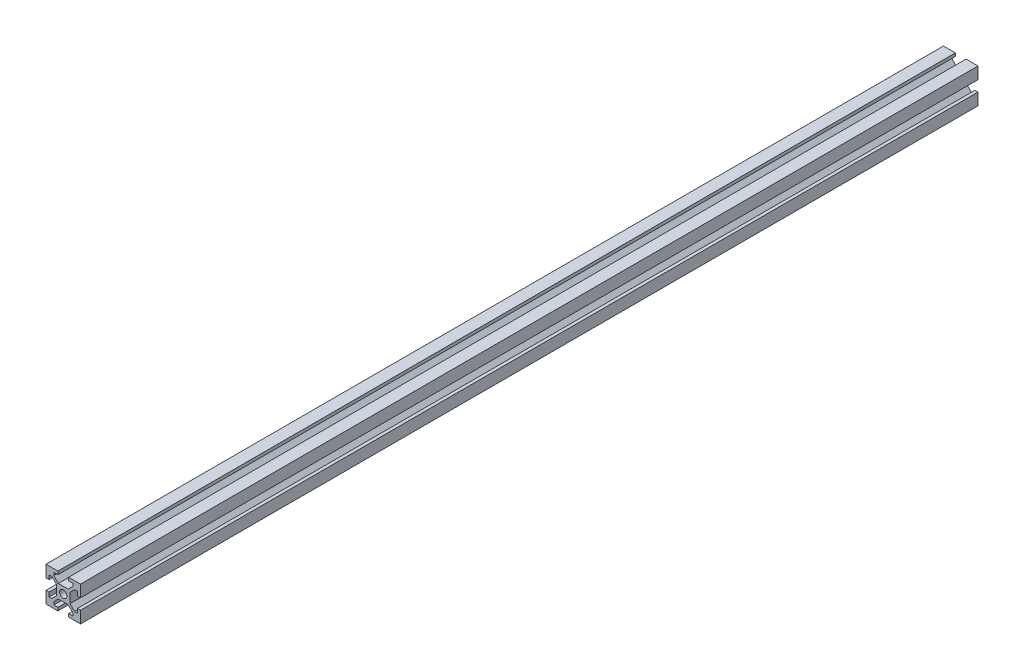
from build123d import *

# Parameters (mm, degrees)
BOSS_EXTRUDE1_DEPTH = 520
SKETCH2_R           = 2.1
CUT_EXTRUDE1_DEPTH  = 521
SKETCH3_R           = 2.1
CUT_EXTRUDE2_DEPTH  = 14.900660172


with BuildPart() as part:
    # Sketch1 → Boss-Extrude1 (new body)
    with BuildSketch(Plane.XY):
        Polygon((-3.1, 10), (-3.1, 8.200660172), (-5.5, 8.200660172), (-5.5, 6.560660172), (-2.84, 3.900660172), (2.84, 3.900660172), (5.5, 6.560660172), (5.5, 8.200660172), (3.1, 8.200660172), (3.1, 10), (10, 10), (10, 3.1), (8.200660172, 3.1), (8.200660172, 5.5), (6.560660172, 5.5), (3.900660172, 2.84), (3.900660172, -2.84), (6.560660172, -5.5), (8.200660172, -5.5), (8.200660172, -3.1), (10, -3.1), (10, -10), (3.1, -10), (3.1, -8.200660172), (5.5, -8.200660172), (5.5, -6.560660172), (2.84, -3.900660172), (-2.84, -3.900660172), (-5.5, -6.560660172), (-5.5, -8.200660172), (-3.1, -8.200660172), (-3.1, -10), (-10, -10), (-10, -3.1), (-8.200660172, -3.1), (-8.200660172, -5.5), (-6.560660172, -5.5), (-3.900660172, -2.84), (-3.900660172, 2.84), (-6.560660172, 5.5), (-8.200660172, 5.5), (-8.200660172, 3.1), (-10, 3.1), (-10, 10), align=None)
    extrude(amount=BOSS_EXTRUDE1_DEPTH)

    # Sketch2 → Cut-Extrude1 (cut, through all)
    with BuildSketch(Plane.XY.offset(520)):
        Circle(SKETCH2_R)
    extrude(amount=-CUT_EXTRUDE1_DEPTH, mode=Mode.SUBTRACT)

    # Sketch3 → Cut-Extrude2 (cut, through all)
    with BuildSketch(Plane(origin=(0, 3.900660172, 0), x_dir=(1, 0, 0), z_dir=(0, 1, 0))):
        with Locations((0, -260)):
            Circle(SKETCH3_R)
    extrude(amount=-CUT_EXTRUDE2_DEPTH, mode=Mode.SUBTRACT)


solid = part.part
